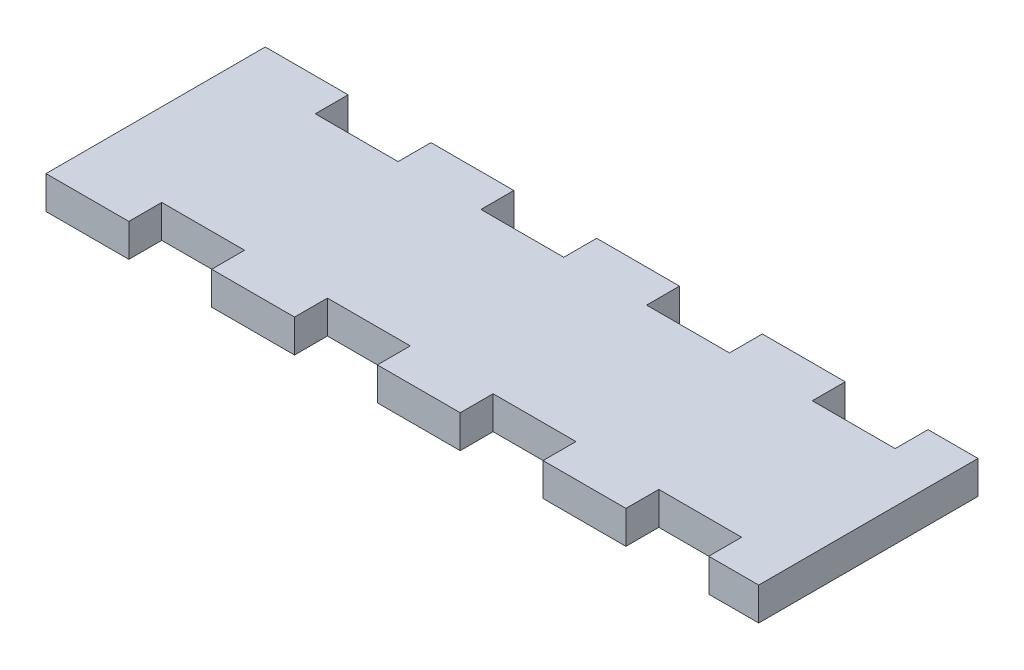
from build123d import *

# Parameters (mm, degrees)
AUFSATZ_LINEAR_AUSTRAGEN1_DEPTH = 3


with BuildPart() as part:
    # Skizze1 → Aufsatz-Linear austragen1 (new body)
    with BuildSketch(Plane(origin=(0, 0, 0), x_dir=(1, 0, 0), z_dir=(0, 1, 0))):
        Polygon((0, 0), (7.555992, 0), (7.555992, 2.999994), (15.11173, 2.999994), (15.11173, 0), (22.667468, 0), (22.667468, 2.999994), (30.221936, 2.999994), (30.221936, 0), (37.777674, 0), (37.777674, 2.999994), (45.333412, 2.999994), (45.333412, 0), (52.88915, 0), (52.88915, 2.999994), (60.444634, 2.999994), (60.444634, 0), (65.000886, 0), (65.000886, 20), (60.444634, 20), (60.444634, 17.000006), (52.88915, 17.000006), (52.88915, 20), (45.333412, 20), (45.333412, 17.000006), (37.777674, 17.000006), (37.777674, 20), (30.221936, 20), (30.221936, 17.000006), (22.667468, 17.000006), (22.667468, 20), (15.11173, 20), (15.11173, 17.000006), (7.555992, 17.000006), (7.555992, 20), (0, 20), align=None)
    extrude(amount=AUFSATZ_LINEAR_AUSTRAGEN1_DEPTH)


solid = part.part
